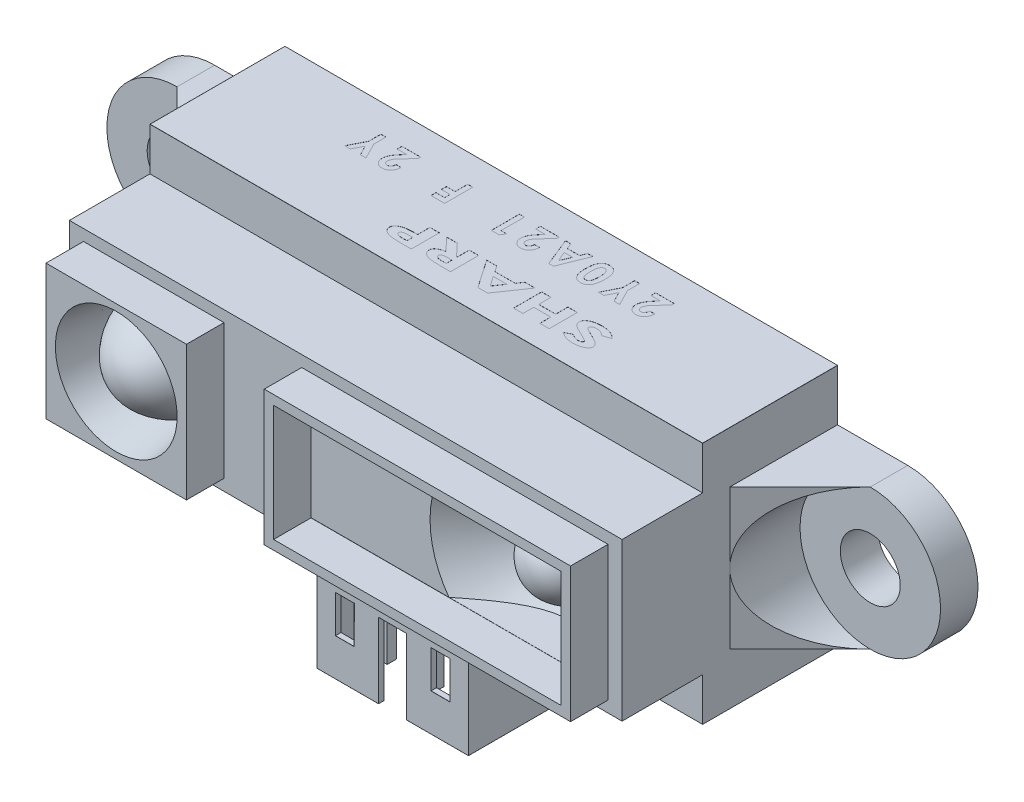
from build123d import *

# Parameters (mm, degrees)
SKETCH1_R           = 1.6
BOSS_EXTRUDE1_DEPTH = 13.5
CUT_EXTRUDE1_START  = -2
SKETCH3_R           = 3.75
CUT_EXTRUDE1_DEPTH  = 12.5
CUT_EXTRUDE2_DEPTH  = 11.25
CUT_EXTRUDE3_START  = -6.3
SKETCH5_W           = 29.5
SKETCH5_H           = 2.3
CUT_EXTRUDE3_DEPTH  = 7.3
CUT_EXTRUDE4_START  = -2
SKETCH6_W           = 29.5
SKETCH6_H           = 8.4
SKETCH6_W_2         = 7.5
SKETCH6_H_2         = 7.2
SKETCH6_W_3         = 16.35
CUT_EXTRUDE4_DEPTH  = 3
SKETCH7_R           = 3.25
CUT_EXTRUDE5_DEPTH  = 3
CUT_EXTRUDE5_TAPER  = 10
SKETCH9_W           = 15.35
SKETCH9_H           = 6.2
CUT_EXTRUDE6_DEPTH  = 2
BOSS_EXTRUDE2_START = -3.3
SKETCH12_W          = 10.1
SKETCH12_H          = 5.9
BOSS_EXTRUDE2_DEPTH = 1.2
SKETCH13_W          = 10.1
SKETCH13_H          = 2.7
CUT_EXTRUDE8_DEPTH  = 2.3
SKETCH14_W          = 8.1
SKETCH14_H          = 4.5
SKETCH14_W_2        = 7.5
SKETCH14_H_2        = 3.9
SKETCH14_W_3        = 0.5
SKETCH14_H_3        = 0.5
BOSS_EXTRUDE3_DEPTH = 8.2
BOSS_EXTRUDE4_START = 1.5
SKETCH15_W          = 7.5
SKETCH15_H          = 3.9
BOSS_EXTRUDE4_DEPTH = 1
CUT_EXTRUDE9_DEPTH  = 4.5
SKETCH17_W          = 8.1
SKETCH17_H          = 0.1
CUT_EXTRUDE10_DEPTH = 0.1
CHAMFER3_SIZE       = 0.05
SKETCH18_W          = 1.5
SKETCH18_H          = 4
SKETCH18_W_2        = 1
SKETCH18_H_2        = 2
CUT_EXTRUDE11_DEPTH = 0.3
FILLET1_R           = 0.005
CUT_EXTRUDE12_DEPTH = 0.005
SKETCH10_R          = 2.25
CUT_EXTRUDE13_DEPTH = 3
BOSS_EXTRUDE5_DEPTH = 4.3


with BuildPart() as part:
    # Sketch1 → Boss-Extrude1 (new body)
    with BuildSketch(Plane.XY):
        with BuildLine():
            Line((-18.5, 3.75), (-14.75, 3.75))
            Line((-14.75, 3.75), (-14.75, 6.5))
            Line((-14.75, 6.5), (14.75, 6.5))
            Line((14.75, 6.5), (14.75, 3.75))
            Line((14.75, 3.75), (18.5, 3.75))
            ThreePointArc((18.5, 3.75), (22.25, 0), (18.5, -3.75))
            Line((18.5, -3.75), (14.75, -3.75))
            Line((14.75, -3.75), (14.75, -6.5))
            Line((14.75, -6.5), (-14.75, -6.5))
            Line((-14.75, -6.5), (-14.75, -3.75))
            Line((-14.75, -3.75), (-18.5, -3.75))
            ThreePointArc((-18.5, -3.75), (-22.25, 0), (-18.5, 3.75))
        make_face()
        with Locations((-18.5, 0)):
            Circle(SKETCH1_R, mode=Mode.SUBTRACT)
        with Locations((18.5, 0)):
            Circle(SKETCH1_R, mode=Mode.SUBTRACT)
    extrude(amount=BOSS_EXTRUDE1_DEPTH)

    # Sketch3 → Cut-Extrude1 (cut, through all)
    with BuildSketch(Plane(origin=(0, 0, 0), x_dir=(-1, 0, 0), z_dir=(0, 0, -1)).offset(CUT_EXTRUDE1_START)):
        with Locations((-18.5, 0)):
            Circle(SKETCH3_R)
        with Locations((18.5, 0)):
            Circle(SKETCH3_R)
    extrude(amount=-CUT_EXTRUDE1_DEPTH, mode=Mode.SUBTRACT)

    # Sketch4 → Cut-Extrude2 (cut, through all)
    with BuildSketch(Plane.XZ.offset(3.75)):
        Polygon((22.25, 2), (18.5, 2), (14.75, 5.75), (14.75, 13.5), (22.25, 13.5), align=None)
        Polygon((-22.25, 2), (-18.5, 2), (-14.75, 5.75), (-14.75, 13.5), (-22.25, 13.5), align=None)
    extrude(amount=-CUT_EXTRUDE2_DEPTH, mode=Mode.SUBTRACT)

    # Sketch5 → Cut-Extrude3 (cut, through all)
    with BuildSketch(Plane.XY.offset(13.5).offset(CUT_EXTRUDE3_START)):
        with Locations((0, 5.35)):
            Rectangle(SKETCH5_W, SKETCH5_H)
        with Locations((0, -5.35)):
            Rectangle(SKETCH5_W, SKETCH5_H)
    extrude(amount=CUT_EXTRUDE3_DEPTH, mode=Mode.SUBTRACT)

    # Sketch6 → Cut-Extrude4 (cut, through all)
    with BuildSketch(Plane.XY.offset(13.5).offset(CUT_EXTRUDE4_START)):
        Rectangle(SKETCH6_W, SKETCH6_H)
        with Locations((-10.25, 0)):
            Rectangle(SKETCH6_W_2, SKETCH6_H_2, mode=Mode.SUBTRACT)
        with Locations((5.825, 0)):
            Rectangle(SKETCH6_W_3, SKETCH6_H_2, mode=Mode.SUBTRACT)
    extrude(amount=CUT_EXTRUDE4_DEPTH, mode=Mode.SUBTRACT)

    # Sketch7 → Cut-Extrude5 (cut)
    with BuildSketch(Plane.XY.offset(13.5)):
        with Locations((-10.25, 0)):
            Circle(SKETCH7_R)
    extrude(amount=-CUT_EXTRUDE5_DEPTH, taper=CUT_EXTRUDE5_TAPER, mode=Mode.SUBTRACT)

    # Sketch8 → Revolve1 (revolve)
    with BuildSketch(Plane(origin=(0, 0, 0), x_dir=(1, 0, 0), z_dir=(0, 1, 0))):
        with BuildLine():
            Line((-10.25, -10.5), (-7.528980942, -10.5))
            add(Edge.make_bspline(
                [(-7.528980942, -10.5), (-7.528980942, -11.5), (-8.583333333, -13.5), (-10.25, -13.5)],
                knots=[0, 0, 0, 0, 1, 1, 1, 1], degree=3))
            Line((-10.25, -13.5), (-10.25, -10.5))
        make_face()
    revolve(axis=Axis((-10.25, 0, 10.5), (0, 0, 1)))

    # Sketch9 → Cut-Extrude6 (cut)
    with BuildSketch(Plane.XY.offset(13.5)):
        with Locations((5.825, 0)):
            Rectangle(SKETCH9_W, SKETCH9_H)
    extrude(amount=-CUT_EXTRUDE6_DEPTH, mode=Mode.SUBTRACT)

    # Sketch12 → Boss-Extrude2 (add)
    with BuildSketch(Plane(origin=(0, 0, 0), x_dir=(-1, 0, 0), z_dir=(0, 0, -1)).offset(BOSS_EXTRUDE2_START)):
        with Locations((0, -9.45)):
            Rectangle(SKETCH12_W, SKETCH12_H)
    extrude(amount=-BOSS_EXTRUDE2_DEPTH)

    # Sketch13 → Cut-Extrude8 (cut)
    with BuildSketch(Plane.XZ.offset(6.5)):
        with Locations((0, 5.85)):
            Rectangle(SKETCH13_W, SKETCH13_H)
    extrude(amount=-CUT_EXTRUDE8_DEPTH, mode=Mode.SUBTRACT)

    # Sketch14 → Boss-Extrude3 (add, through all)
    with BuildSketch(Plane.XZ.offset(4.2)):
        with Locations((0, 6.75)):
            Rectangle(SKETCH14_W, SKETCH14_H)
        with Locations((0, 6.75)):
            Rectangle(SKETCH14_W_2, SKETCH14_H_2, mode=Mode.SUBTRACT)
        with Locations((0, 6.75)):
            Rectangle(SKETCH14_W_3, SKETCH14_H_3)
        with Locations((2.54, 6.75)):
            Rectangle(SKETCH14_W_3, SKETCH14_H_3)
        with Locations((-2.54, 6.75)):
            Rectangle(SKETCH14_W_3, SKETCH14_H_3)
    extrude(amount=BOSS_EXTRUDE3_DEPTH)

    # Sketch15 → Boss-Extrude4 (add)
    with BuildSketch(Plane.XZ.offset(4.2).offset(BOSS_EXTRUDE4_START)):
        with Locations((0, 6.75)):
            Rectangle(SKETCH15_W, SKETCH15_H)
    extrude(amount=BOSS_EXTRUDE4_DEPTH)

    # Sketch16 → Cut-Extrude9 (cut)
    with BuildSketch(Plane.XY.offset(9)):
        Polygon((-4.05, -4.2), (-4.05, -4.860219994), (-3.55, -4.860219994), (-3.55, -5.760219994), (3.55, -5.760219994), (3.55, -4.8), (4.05, -4.8), (4.05, -4.2), align=None)
    extrude(amount=-CUT_EXTRUDE9_DEPTH, mode=Mode.SUBTRACT)

    # Sketch17 → Cut-Extrude10 (cut)
    with BuildSketch(Plane(origin=(0, -12.4, 0), x_dir=(-1, 0, 0), z_dir=(0, -1, 0))):
        with Locations((0, -4.55)):
            Rectangle(SKETCH17_W, SKETCH17_H)
    extrude(amount=-CUT_EXTRUDE10_DEPTH, mode=Mode.SUBTRACT)

    # Chamfer3
    chamfer3_edges = [part.edges().sort_by_distance(p)[0] for p in [
        (0.25, -12.4, 6.75),
        (0, -12.4, 7),
        (-0.25, -12.4, 6.75),
        (0, -12.4, 6.5),
        (2.54, -12.4, 7),
        (2.79, -12.4, 6.75),
        (2.29, -12.4, 6.75),
        (2.54, -12.4, 6.5),
        (-2.29, -12.4, 6.75),
        (-2.54, -12.4, 7),
        (-2.79, -12.4, 6.75),
        (-2.54, -12.4, 6.5),
    ]]
    chamfer(chamfer3_edges, length=CHAMFER3_SIZE)

    # Sketch18 → Cut-Extrude11 (cut)
    with BuildSketch(Plane.XY.offset(9)):
        with Locations((0, -10.4)):
            Rectangle(SKETCH18_W, SKETCH18_H)
        with Locations((-2.55, -9.4)):
            Rectangle(SKETCH18_W_2, SKETCH18_H_2)
        with Locations((2.55, -9.4)):
            Rectangle(SKETCH18_W_2, SKETCH18_H_2)
    extrude(amount=-CUT_EXTRUDE11_DEPTH, mode=Mode.SUBTRACT)

    # Fillet1
    fillet1_edges = [part.edges().sort_by_distance(p)[0] for p in [
        (14.75, 6.5, 3.6),
        (-14.75, 6.5, 3.6),
        (0, 6.5, 7.2),
        (13.5, 0, 11.5),
        (5.825, -3.1, 11.5),
        (-2.4, -12.4, 9),
        (4.05, -8.6, 9),
        (3.75, -12.4, 6.75),
        (3.75, -9.55, 8.7),
        (0, -12.4, 4.8),
        (-3.75, -9.55, 8.7),
        (-4.05, -8.630109997, 9),
        (-3.75, -12.4, 6.75),
        (-2.25, -12.4, 8.7),
        (0, -6.7, 8.7),
        (-4.05, -4.860219994, 6.75),
        (-3.8, -4.860219994, 9),
        (-3.55, -5.310219994, 9),
        (0, -5.760219994, 9),
        (3.55, -5.280109997, 9),
        (3.8, -4.8, 9),
        (-3.8, -4.860219994, 4.5),
        (-4.05, -8.580109997, 4.5),
        (-4.05, -12.4, 6.8),
        (4.05, -12.4, 6.8),
        (0, -12.3, 4.5),
        (-4.05, -12.3, 4.55),
        (-4.05, -12.35, 4.6),
        (0, -12.4, 4.6),
        (2.4, -12.4, 9),
        (2.25, -12.4, 8.7),
        (2.05, -9.4, 9),
        (2.55, -10.4, 9),
        (3.05, -9.4, 9),
        (2.55, -8.4, 9),
        (2.05, -9.4, 8.7),
        (2.55, -8.4, 8.7),
        (3.05, -9.4, 8.7),
        (2.55, -10.4, 8.7),
        (-3.05, -9.4, 9),
        (-2.55, -10.4, 9),
        (-2.05, -9.4, 9),
        (-2.55, -8.4, 9),
        (-3.05, -9.4, 8.7),
        (-2.55, -8.4, 8.7),
        (-2.05, -9.4, 8.7),
        (-2.55, -10.4, 8.7),
        (-0.75, -12.4, 8.85),
        (0.75, -12.4, 8.85),
        (-0.75, -10.4, 9),
        (0.75, -10.4, 9),
        (0, -8.4, 9),
        (-0.75, -10.4, 8.7),
        (0, -8.4, 8.7),
        (0.75, -10.4, 8.7),
    ]]
    fillet(fillet1_edges, radius=FILLET1_R)

    # Sketch19 → Cut-Extrude12 (cut)
    with BuildSketch(Plane(origin=(0, 6.5, 0), x_dir=(1, 0, 0), z_dir=(0, 1, 0))):
        with BuildLine():
            Line((-2.003855433, -6), (-2.546223222, -6))
            add(Edge.make_bspline(
                [(-2.546223222, -6), (-2.581580758, -5.999913513), (-2.649798708, -5.999746648), (-2.748373771, -5.997668262), (-2.839227685, -5.994046889), (-2.922497136, -5.989412392), (-2.99793639, -5.983118091), (-3.065810461, -5.975780196), (-3.125983937, -5.966907417), (-3.1793444, -5.956377265), (-3.22747068, -5.943944163), (-3.272442089, -5.930660255), (-3.314685073, -5.914940864), (-3.354446077, -5.897876093), (-3.391624287, -5.879198773), (-3.426247625, -5.858844358), (-3.458236639, -5.836471428), (-3.487671043, -5.812575415), (-3.514019403, -5.78715296), (-3.537223483, -5.760593813), (-3.556520535, -5.732534132), (-3.572252501, -5.703168237), (-3.58461326, -5.672642205), (-3.593861938, -5.640883349), (-3.598879578, -5.607732702), (-3.599630645, -5.585251619), (-3.60000928, -5.573918269)],
                knots=[0, 0, 0, 0, 0.000106071, 0.000204652, 0.000295769, 0.000378841, 0.000454824, 0.000522848, 0.000583617, 0.000637242, 0.000685925, 0.000732694, 0.000777851, 0.000821054, 0.000862443, 0.000902588, 0.000941432, 0.000979445, 0.001016208, 0.001051147, 0.001085069, 0.00111814, 0.001150894, 0.001183707, 0.001217152, 0.001251154, 0.001251154, 0.001251154, 0.001251154], degree=3))
            add(Edge.make_bspline(
                [(-3.60000928, -5.573918269), (-3.599541213, -5.561364202), (-3.598616557, -5.536563911), (-3.591447175, -5.500311612), (-3.580118651, -5.465482861), (-3.563151829, -5.432737203), (-3.542450632, -5.401095142), (-3.516451786, -5.3716555), (-3.486308918, -5.343469381), (-3.451192625, -5.317658038), (-3.41254664, -5.292965856), (-3.370142717, -5.270581921), (-3.324454668, -5.250247369), (-3.2758844, -5.231083213), (-3.223522746, -5.214848406), (-3.168154519, -5.199768485), (-3.109397216, -5.186779698), (-3.068994361, -5.180099763), (-3.048326587, -5.176682692)],
                knots=[0, 0, 0, 0, 3.7637e-05, 7.4351e-05, 0.000110459, 0.000147144, 0.000184647, 0.000223627, 0.000264661, 0.000308231, 0.000354161, 0.00040215, 0.000451911, 0.00050414, 0.000558687, 0.000616271, 0.000676272, 0.000739109, 0.000739109, 0.000739109, 0.000739109], degree=3))
            add(Edge.make_bspline(
                [(-3.048326587, -5.176682692), (-3.034617929, -5.174764841), (-3.004669622, -5.170575051), (-2.955715955, -5.166443334), (-2.899121518, -5.162525243), (-2.834910763, -5.159225428), (-2.762980257, -5.156965579), (-2.683449491, -5.155197826), (-2.596207293, -5.153914008), (-2.535506584, -5.153869409), (-2.503855433, -5.153846154)],
                knots=[0, 0, 0, 0, 4.152e-05, 9.0705e-05, 0.00014733, 0.000211718, 0.000283573, 0.000363221, 0.000450369, 0.000545321, 0.000545321, 0.000545321, 0.000545321], degree=3))
            Line((-2.503855433, -5.153846154), (-2.503855433, -4.5))
            Line((-2.503855433, -4.5), (-2.003855433, -4.5))
            Line((-2.003855433, -4.5), (-2.003855433, -6))
        make_face()
        with BuildLine():
            Line((-2.503855433, -5.423076923), (-2.668218414, -5.423076923))
            add(Edge.make_bspline(
                [(-2.668218414, -5.423076923), (-2.683743374, -5.423158943), (-2.713592464, -5.423316639), (-2.756466468, -5.423832122), (-2.795739089, -5.424988596), (-2.831290326, -5.426871964), (-2.863172026, -5.428777624), (-2.891302901, -5.431625648), (-2.915802646, -5.434386248), (-2.942985481, -5.439128581), (-2.972620877, -5.446527626), (-3.00453605, -5.458006032), (-3.03274044, -5.471599342), (-3.056606604, -5.488089677), (-3.07582799, -5.506663052), (-3.089951675, -5.527294434), (-3.098513669, -5.550142582), (-3.09950714, -5.566135363), (-3.10000928, -5.57421875)],
                knots=[0, 0, 0, 0, 4.6575e-05, 8.9548e-05, 0.000128629, 0.000164432, 0.000196352, 0.000224428, 0.00024925, 0.000270294, 0.00030717, 0.000340723, 0.000371899, 0.000400824, 0.000427383, 0.000451635, 0.000475304, 0.000499495, 0.000499495, 0.000499495, 0.000499495], degree=3))
            add(Edge.make_bspline(
                [(-3.10000928, -5.57421875), (-3.099702522, -5.581270971), (-3.099100084, -5.595120787), (-3.093118924, -5.615088061), (-3.083290219, -5.63338096), (-3.069669431, -5.650183869), (-3.052411291, -5.665642105), (-3.030933307, -5.678914172), (-3.006247574, -5.691524557), (-2.987928279, -5.697753023), (-2.978314568, -5.701021635)],
                knots=[0, 0, 0, 0, 2.1111e-05, 4.1459e-05, 6.1892e-05, 8.3056e-05, 0.000106039, 0.000131044, 0.000158591, 0.000189013, 0.000189013, 0.000189013, 0.000189013], degree=3))
            add(Edge.make_bspline(
                [(-2.978314568, -5.701021635), (-2.970132043, -5.703445815), (-2.952433817, -5.708689146), (-2.923060231, -5.714444989), (-2.889069516, -5.719501788), (-2.850268178, -5.723618824), (-2.806775834, -5.726826247), (-2.758588652, -5.729296801), (-2.705682134, -5.730281745), (-2.66881944, -5.730602104), (-2.649588607, -5.730769231)],
                knots=[0, 0, 0, 0, 2.559e-05, 5.535e-05, 8.9686e-05, 0.000128676, 0.000172371, 0.000220508, 0.000273406, 0.000331102, 0.000331102, 0.000331102, 0.000331102], degree=3))
            Line((-2.649588607, -5.730769231), (-2.503855433, -5.730769231))
            Line((-2.503855433, -5.730769231), (-2.503855433, -5.423076923))
        make_face(mode=Mode.SUBTRACT)
        with BuildLine():
            Line((0.092298413, -6), (-0.443458799, -6))
            add(Edge.make_bspline(
                [(-0.443458799, -6), (-0.47881685, -5.999926021), (-0.546935654, -5.999783497), (-0.645099744, -5.997550308), (-0.735372204, -5.994473365), (-0.817711835, -5.989588475), (-0.89218974, -5.983851715), (-0.958714867, -5.976290334), (-1.017420532, -5.967869191), (-1.069060773, -5.957546333), (-1.11555333, -5.945523387), (-1.158862835, -5.931964949), (-1.200089034, -5.916958483), (-1.238561597, -5.899030986), (-1.275412562, -5.880896287), (-1.309452032, -5.859841867), (-1.341414669, -5.837319325), (-1.371048585, -5.813145387), (-1.397881313, -5.78756251), (-1.420703733, -5.760232259), (-1.44067635, -5.732234491), (-1.45640833, -5.702609966), (-1.469435292, -5.672175495), (-1.477876267, -5.64037163), (-1.483675442, -5.607583262), (-1.484304799, -5.585262555), (-1.484624664, -5.573918269)],
                knots=[0, 0, 0, 0, 0.000106071, 0.000204351, 0.000294556, 0.000377028, 0.000451789, 0.000518619, 0.000577857, 0.000629656, 0.000676517, 0.00072185, 0.000765776, 0.000808002, 0.000849123, 0.000888906, 0.000927924, 0.00096636, 0.001003548, 0.001038943, 0.001073037, 0.001106514, 0.001139382, 0.001172114, 0.001205014, 0.001239016, 0.001239016, 0.001239016, 0.001239016], degree=3))
            add(Edge.make_bspline(
                [(-1.484624664, -5.573918269), (-1.484214129, -5.5620723), (-1.483405046, -5.538726217), (-1.477176426, -5.504531248), (-1.467287243, -5.471665063), (-1.452994692, -5.440506138), (-1.435209361, -5.410484131), (-1.412522069, -5.38273902), (-1.386765533, -5.355656408), (-1.356218125, -5.330796298), (-1.322061936, -5.307011251), (-1.283547706, -5.285231483), (-1.241384508, -5.264399854), (-1.195033875, -5.245168201), (-1.144416064, -5.228009095), (-1.090026557, -5.211737733), (-1.031585238, -5.196959676), (-0.991072175, -5.188733146), (-0.970201587, -5.184495192)],
                knots=[0, 0, 0, 0, 3.5519e-05, 7.0001e-05, 0.000103934, 0.000138227, 0.000172599, 0.000208311, 0.000245499, 0.000284549, 0.000326225, 0.000370241, 0.00041714, 0.000467251, 0.000520655, 0.000577411, 0.000637535, 0.000701418, 0.000701418, 0.000701418, 0.000701418], degree=3))
            Line((-0.970201587, -5.184495192), (-1.609624664, -4.5))
            Line((-1.609624664, -4.5), (-1.044420337, -4.5))
            Line((-1.044420337, -4.5), (-0.433843414, -5.153846154))
            Line((-0.433843414, -5.153846154), (-0.407701587, -5.153846154))
            Line((-0.407701587, -5.153846154), (-0.407701587, -4.5))
            Line((-0.407701587, -4.5), (0.092298413, -4.5))
            Line((0.092298413, -4.5), (0.092298413, -6))
        make_face()
        with BuildLine():
            Line((-0.407701587, -5.423076923), (-0.56485303, -5.423076923))
            add(Edge.make_bspline(
                [(-0.56485303, -5.423076923), (-0.583983899, -5.423222702), (-0.620749359, -5.423502859), (-0.673666876, -5.424775991), (-0.721952419, -5.427877738), (-0.765537675, -5.431746727), (-0.804509217, -5.436264996), (-0.838672686, -5.442648017), (-0.868369779, -5.449648844), (-0.89364385, -5.458044117), (-0.915217351, -5.467801306), (-0.933721429, -5.478938995), (-0.949578623, -5.491514791), (-0.962381966, -5.505898992), (-0.972549638, -5.521645335), (-0.979369574, -5.539036921), (-0.983802598, -5.557772835), (-0.984344242, -5.570786528), (-0.984624664, -5.577524038)],
                knots=[0, 0, 0, 0, 5.7395e-05, 0.000110301, 0.000158772, 0.000202516, 0.000241575, 0.000276406, 0.000306724, 0.000333044, 0.000356172, 0.000377609, 0.000397694, 0.000416634, 0.00043514, 0.000453609, 0.000472415, 0.000492603, 0.000492603, 0.000492603, 0.000492603], degree=3))
            add(Edge.make_bspline(
                [(-0.984624664, -5.577524038), (-0.984159255, -5.585524164), (-0.983236194, -5.601391065), (-0.973976303, -5.624026924), (-0.959969223, -5.645153627), (-0.939983181, -5.663965775), (-0.915594807, -5.680522025), (-0.887398802, -5.695125434), (-0.855200729, -5.706585633), (-0.825542617, -5.714510223), (-0.798286965, -5.71905815), (-0.773648467, -5.722388748), (-0.745075575, -5.725015662), (-0.712602195, -5.726987952), (-0.676347352, -5.728858701), (-0.63617402, -5.730016843), (-0.592097989, -5.730529883), (-0.561347522, -5.730687229), (-0.54532178, -5.730769231)],
                knots=[0, 0, 0, 0, 2.3892e-05, 4.7385e-05, 7.2303e-05, 9.9503e-05, 0.000129092, 0.000160539, 0.000194478, 0.000231428, 0.000252473, 0.000277333, 0.000306006, 0.000338526, 0.000374929, 0.000414911, 0.000459086, 0.000507164, 0.000507164, 0.000507164, 0.000507164], degree=3))
            Line((-0.54532178, -5.730769231), (-0.407701587, -5.730769231))
            Line((-0.407701587, -5.730769231), (-0.407701587, -5.423076923))
        make_face(mode=Mode.SUBTRACT)
        Polygon((2.073067643, -6), (1.552935432, -6), (0.52499072, -4.5), (1.061348893, -4.5), (1.268981105, -4.807692308), (2.358524374, -4.807692308), (2.566156586, -4.5), (3.101913797, -4.5), align=None)
        Polygon((1.813452259, -5.59765625), (2.176433028, -5.076923077), (1.45077197, -5.076923077), align=None, mode=Mode.SUBTRACT)
        Polygon((5.361529182, -6), (4.861529182, -6), (4.861529182, -5.423076923), (3.957683028, -5.423076923), (3.957683028, -6), (3.457683028, -6), (3.457683028, -4.5), (3.957683028, -4.5), (3.957683028, -5.153846154), (4.861529182, -5.153846154), (4.861529182, -4.5), (5.361529182, -4.5), align=None)
        with BuildLine():
            Line((5.89999072, -5.799579327), (6.266577259, -5.615384615))
            add(Edge.make_bspline(
                [(6.266577259, -5.615384615), (6.282528593, -5.627647975), (6.313772624, -5.651668336), (6.362611113, -5.682820968), (6.411413867, -5.709546949), (6.460554008, -5.731294361), (6.510006159, -5.748273331), (6.559697604, -5.760267867), (6.609593131, -5.767845771), (6.642953272, -5.768769606), (6.659606105, -5.769230769)],
                knots=[0, 0, 0, 0, 6.0337e-05, 0.000118182, 0.000173578, 0.000227122, 0.000279195, 0.00033021, 0.000380311, 0.000430249, 0.000430249, 0.000430249, 0.000430249], degree=3))
            add(Edge.make_bspline(
                [(6.659606105, -5.769230769), (6.675152539, -5.768952342), (6.704859034, -5.768420318), (6.747133789, -5.76258908), (6.785090502, -5.753586071), (6.8178813, -5.74050972), (6.844759539, -5.725227591), (6.865157897, -5.709005451), (6.878087239, -5.690545019), (6.879904737, -5.677236032), (6.880759951, -5.670973558)],
                knots=[0, 0, 0, 0, 4.6609e-05, 8.9062e-05, 0.00012776, 0.000163359, 0.000194592, 0.000220177, 0.000241264, 0.000260005, 0.000260005, 0.000260005, 0.000260005], degree=3))
            add(Edge.make_bspline(
                [(6.880759951, -5.670973558), (6.880230063, -5.66467259), (6.879132485, -5.651621139), (6.869834585, -5.632835943), (6.855334387, -5.614896971), (6.842723174, -5.604637561), (6.835988317, -5.599158654)],
                knots=[0, 0, 0, 0, 1.8825e-05, 3.8993e-05, 6.1659e-05, 8.7636e-05, 8.7636e-05, 8.7636e-05, 8.7636e-05], degree=3))
            add(Edge.make_bspline(
                [(6.835988317, -5.599158654), (6.829721398, -5.594785833), (6.814901415, -5.584445005), (6.788015331, -5.568472271), (6.753408922, -5.549400949), (6.711324568, -5.526885065), (6.661653213, -5.501022195), (6.604373272, -5.471944576), (6.539319621, -5.439787441), (6.49335373, -5.417439968), (6.469101297, -5.405649038)],
                knots=[0, 0, 0, 0, 2.2919e-05, 5.42e-05, 9.3746e-05, 0.000141469, 0.000197379, 0.000261748, 0.000334179, 0.000415079, 0.000415079, 0.000415079, 0.000415079], degree=3))
            add(Edge.make_bspline(
                [(6.469101297, -5.405649038), (6.446360054, -5.394741593), (6.403261391, -5.374070061), (6.342142694, -5.344566503), (6.288066243, -5.318302716), (6.24131062, -5.29462369), (6.201225179, -5.27503256), (6.168410081, -5.258124992), (6.142620254, -5.244479346), (6.127940074, -5.23610557), (6.121745528, -5.232572115)],
                knots=[0, 0, 0, 0, 7.5665e-05, 0.000143399, 0.000203603, 0.000256011, 0.000300625, 0.000337447, 0.000366753, 0.000388146, 0.000388146, 0.000388146, 0.000388146], degree=3))
            add(Edge.make_bspline(
                [(6.121745528, -5.232572115), (6.109479365, -5.225336163), (6.085653095, -5.21128077), (6.051730658, -5.189568021), (6.020314073, -5.16845967), (5.992199808, -5.146841727), (5.966132681, -5.126389702), (5.943298975, -5.10564792), (5.923388743, -5.085033852), (5.900323388, -5.058815749), (5.877329028, -5.024389108), (5.857101939, -4.980865912), (5.844463742, -4.935299883), (5.843020657, -4.904124498), (5.842298413, -4.888521635)],
                knots=[0, 0, 0, 0, 4.272e-05, 8.2981e-05, 0.000120819, 0.000156216, 0.000189347, 0.000220191, 0.000248665, 0.000275293, 0.00032488, 0.000372204, 0.000418851, 0.000465589, 0.000465589, 0.000465589, 0.000465589], degree=3))
            add(Edge.make_bspline(
                [(5.842298413, -4.888521635), (5.842987999, -4.87333268), (5.844352223, -4.843284029), (5.855418316, -4.799365337), (5.872886933, -4.757531458), (5.897806228, -4.717891354), (5.929833061, -4.680562623), (5.968493312, -4.644965965), (6.014464422, -4.612023686), (6.066472414, -4.580951875), (6.124336137, -4.552967934), (6.186818049, -4.52837447), (6.253648446, -4.507711375), (6.324554885, -4.490467036), (6.399930017, -4.477940366), (6.479308525, -4.468202227), (6.562966545, -4.46246126), (6.62013416, -4.461850843), (6.649389759, -4.461538462)],
                knots=[0, 0, 0, 0, 4.5516e-05, 9.0045e-05, 0.000135024, 0.000181049, 0.000229872, 0.000282184, 0.000338319, 0.00039923, 0.000463735, 0.000530917, 0.000600484, 0.000673437, 0.00074966, 0.000829568, 0.000913296, 0.001001055, 0.001001055, 0.001001055, 0.001001055], degree=3))
            add(Edge.make_bspline(
                [(6.649389759, -4.461538462), (6.672431386, -4.461763099), (6.717842312, -4.46220582), (6.784799851, -4.465887065), (6.849557337, -4.471849574), (6.911922774, -4.4802028), (6.972119264, -4.490973412), (7.029916554, -4.504573655), (7.085626289, -4.5200975), (7.139066765, -4.538076986), (7.190268488, -4.559105833), (7.239944575, -4.581845186), (7.287241189, -4.608439481), (7.333081589, -4.637006741), (7.376534514, -4.66926054), (7.418844158, -4.703202198), (7.458583149, -4.740796807), (7.483560476, -4.767497276), (7.496144567, -4.780949519)],
                knots=[0, 0, 0, 0, 6.9121e-05, 0.000136225, 0.000201107, 0.000264171, 0.000324937, 0.000384486, 0.000442229, 0.000498387, 0.000553516, 0.000608228, 0.000662162, 0.000716182, 0.000770152, 0.000824402, 0.000878822, 0.000934079, 0.000934079, 0.000934079, 0.000934079], degree=3))
            Line((7.496144567, -4.780949519), (7.078476297, -4.923076923))
            add(Edge.make_bspline(
                [(7.078476297, -4.923076923), (7.0627281, -4.907741051), (7.031839986, -4.877661661), (6.981636561, -4.8386646), (6.93002863, -4.805124426), (6.876372465, -4.778094405), (6.820951416, -4.756732749), (6.763695935, -4.74184063), (6.704688219, -4.732440837), (6.664749543, -4.731330106), (6.644582067, -4.730769231)],
                knots=[0, 0, 0, 0, 6.5901e-05, 0.000129256, 0.000190351, 0.000250285, 0.000309158, 0.000368193, 0.000427476, 0.000487948, 0.000487948, 0.000487948, 0.000487948], degree=3))
            add(Edge.make_bspline(
                [(6.644582067, -4.730769231), (6.624117814, -4.731239715), (6.584619361, -4.732147807), (6.528032414, -4.740422849), (6.476193696, -4.753299352), (6.437299622, -4.769412451), (6.409412585, -4.78390988), (6.391701312, -4.795385869), (6.376393511, -4.806923026), (6.364306959, -4.819485894), (6.354512122, -4.832063833), (6.347279873, -4.845159872), (6.343337549, -4.858952626), (6.342643377, -4.868267613), (6.342298413, -4.872896635)],
                knots=[0, 0, 0, 0, 6.1358e-05, 0.000118428, 0.000171193, 0.000221189, 0.000244309, 0.000265396, 0.00028445, 0.000301661, 0.000317527, 0.00033218, 0.000346254, 0.000360158, 0.000360158, 0.000360158, 0.000360158], degree=3))
            add(Edge.make_bspline(
                [(6.342298413, -4.872896635), (6.343195503, -4.881543751), (6.345075351, -4.899663733), (6.35878569, -4.925948103), (6.3802125, -4.951483267), (6.40407459, -4.972501657), (6.428930972, -4.989646209), (6.453034651, -5.004898053), (6.481952112, -5.022189208), (6.516194261, -5.040422046), (6.555115926, -5.061128276), (6.599142268, -5.083173944), (6.648189557, -5.106876101), (6.682530481, -5.123122722), (6.70047149, -5.131610577)],
                knots=[0, 0, 0, 0, 2.5885e-05, 5.4242e-05, 8.7139e-05, 0.000125667, 0.000149176, 0.000177683, 0.000211231, 0.000250224, 0.000294042, 0.000343494, 0.000397921, 0.000457463, 0.000457463, 0.000457463, 0.000457463], degree=3))
            add(Edge.make_bspline(
                [(6.70047149, -5.131610577), (6.718017512, -5.139785747), (6.752375426, -5.155794035), (6.802469329, -5.179916179), (6.850330464, -5.202980751), (6.895714819, -5.22550153), (6.938604436, -5.247494679), (6.9792676, -5.26844441), (7.01748416, -5.288968181), (7.053369494, -5.308654948), (7.086917136, -5.327703163), (7.118003047, -5.345880335), (7.146732482, -5.363444493), (7.173166668, -5.380143625), (7.197126544, -5.39640259), (7.218878207, -5.411677684), (7.238176947, -5.426354445), (7.260086298, -5.444931521), (7.284702641, -5.467043224), (7.309852693, -5.49461673), (7.331737628, -5.521601839), (7.34982769, -5.548697125), (7.363213535, -5.576226452), (7.373528564, -5.603374593), (7.37935345, -5.630764618), (7.380294062, -5.649013933), (7.380759951, -5.658052885)],
                knots=[0, 0, 0, 0, 5.8071e-05, 0.000113711, 0.000166795, 0.000217457, 0.0002657, 0.000311394, 0.000354681, 0.000395833, 0.000434184, 0.000470413, 0.000503858, 0.0005352, 0.000564202, 0.000590715, 0.000614935, 0.000636903, 0.000676883, 0.000714096, 0.000748728, 0.000781064, 0.000811569, 0.000840373, 0.000868012, 0.000895137, 0.000895137, 0.000895137, 0.000895137], degree=3))
            add(Edge.make_bspline(
                [(7.380759951, -5.658052885), (7.380113626, -5.670934294), (7.378827905, -5.696559012), (7.368713265, -5.73419384), (7.352277457, -5.770323297), (7.329005831, -5.804904148), (7.299038803, -5.837681516), (7.263038291, -5.869412409), (7.220254798, -5.899229918), (7.172054436, -5.927878422), (7.118876933, -5.953609972), (7.062233544, -5.97662074), (7.002423715, -5.995707408), (6.93956911, -6.01132063), (6.873760946, -6.023643115), (6.804826825, -6.032258548), (6.732901959, -6.037395134), (6.683953552, -6.038101508), (6.659005143, -6.038461538)],
                knots=[0, 0, 0, 0, 3.8603e-05, 7.6793e-05, 0.000116059, 0.000157228, 0.000201272, 0.000248959, 0.0003009, 0.000357483, 0.000417016, 0.000477947, 0.000540759, 0.000605183, 0.000672131, 0.000741491, 0.000813487, 0.000888329, 0.000888329, 0.000888329, 0.000888329], degree=3))
            add(Edge.make_bspline(
                [(6.659005143, -6.038461538), (6.626629125, -6.037819411), (6.562534854, -6.036548201), (6.467655275, -6.02662244), (6.375047053, -6.010800689), (6.299435754, -5.991989001), (6.239384146, -5.973087634), (6.193532464, -5.956316263), (6.146790142, -5.936589191), (6.099192579, -5.914418182), (6.050605969, -5.889624486), (6.001087225, -5.862293236), (5.950553494, -5.832267011), (5.917048997, -5.810607115), (5.89999072, -5.799579327)],
                knots=[0, 0, 0, 0, 9.7112e-05, 0.00019225, 0.000285862, 0.000378781, 0.000425727, 0.000474683, 0.000525187, 0.000577885, 0.000632175, 0.000688795, 0.000747542, 0.000808475, 0.000808475, 0.000808475, 0.000808475], degree=3))
        make_face()
        Polygon((-7.419640926, -3), (-7.719220253, -3), (-7.986948618, -2.473858173), (-8.254676983, -3), (-8.55425631, -3), (-8.121564003, -2.149639423), (-8.121564003, -1.5), (-7.852333233, -1.5), (-7.852333233, -2.149639423), align=None)
        with BuildLine():
            Line((-6.310025541, -2.5), (-6.040794772, -2.5))
            add(Edge.make_bspline(
                [(-6.040794772, -2.5), (-6.041957082, -2.520366096), (-6.044228165, -2.560160226), (-6.053271871, -2.6179589), (-6.065358988, -2.672585653), (-6.081628547, -2.723876258), (-6.101668158, -2.771852262), (-6.125976584, -2.816354748), (-6.153828063, -2.857702596), (-6.185783993, -2.895170649), (-6.220547437, -2.928855567), (-6.258029275, -2.958303807), (-6.298123034, -2.982955836), (-6.340560616, -3.003178007), (-6.385175331, -3.019358348), (-6.432417948, -3.030170521), (-6.481871613, -3.037494214), (-6.515726951, -3.038134963), (-6.532982272, -3.038461538)],
                knots=[0, 0, 0, 0, 6.1164e-05, 0.000119511, 0.000175275, 0.000228872, 0.000280717, 0.000331005, 0.00038076, 0.000430007, 0.000478458, 0.000525763, 0.000572713, 0.000619349, 0.000666586, 0.000714761, 0.000764522, 0.000816248, 0.000816248, 0.000816248, 0.000816248], degree=3))
            add(Edge.make_bspline(
                [(-6.532982272, -3.038461538), (-6.554171978, -3.03784399), (-6.595557426, -3.036637862), (-6.655501721, -3.02502507), (-6.711842113, -3.007136816), (-6.764021849, -2.981408401), (-6.811767445, -2.948816666), (-6.854511309, -2.909539434), (-6.892449614, -2.864058493), (-6.924331664, -2.812706264), (-6.950263323, -2.758139947), (-6.968986571, -2.70204613), (-6.981147626, -2.645555819), (-6.982453652, -2.607531625), (-6.983102464, -2.588641827)],
                knots=[0, 0, 0, 0, 6.3504e-05, 0.000124029, 0.000182468, 0.000240387, 0.000297895, 0.000355319, 0.000413989, 0.000475016, 0.000536173, 0.000594801, 0.000652139, 0.000708744, 0.000708744, 0.000708744, 0.000708744], degree=3))
            add(Edge.make_bspline(
                [(-6.983102464, -2.588641827), (-6.982850808, -2.57721528), (-6.982344286, -2.554216465), (-6.978822371, -2.519413612), (-6.973538804, -2.483962837), (-6.965572469, -2.447894538), (-6.955637807, -2.411198595), (-6.943585587, -2.373765223), (-6.929136429, -2.335806531), (-6.912530746, -2.29689579), (-6.892722517, -2.256904706), (-6.869648744, -2.21524191), (-6.84267275, -2.17179276), (-6.812057899, -2.126692529), (-6.77801985, -2.079591454), (-6.740040506, -2.031047374), (-6.698606292, -1.980512232), (-6.669189577, -1.946738895), (-6.654076022, -1.929387019)],
                knots=[0, 0, 0, 0, 3.4276e-05, 6.8989e-05, 0.000104856, 0.00014175, 0.000179726, 0.000218876, 0.000259672, 0.000301534, 0.000345746, 0.000393493, 0.000444359, 0.000499114, 0.000556994, 0.000618662, 0.00068399, 0.00075302, 0.00075302, 0.00075302, 0.00075302], degree=3))
            Line((-6.654076022, -1.929387019), (-6.497525541, -1.75))
            Line((-6.497525541, -1.75), (-7.002333233, -1.75))
            Line((-7.002333233, -1.75), (-7.002333233, -1.5))
            Line((-7.002333233, -1.5), (-6.002333233, -1.5))
            Line((-6.002333233, -1.5), (-6.002333233, -1.636418269))
            Line((-6.002333233, -1.636418269), (-6.44644381, -2.109074519))
            add(Edge.make_bspline(
                [(-6.44644381, -2.109074519), (-6.459302156, -2.122861912), (-6.48420496, -2.149564002), (-6.519635775, -2.188781103), (-6.551709333, -2.225989162), (-6.579708473, -2.261619671), (-6.605327223, -2.294466226), (-6.626759192, -2.325770552), (-6.645423811, -2.354651066), (-6.664920977, -2.389855262), (-6.68386299, -2.431525413), (-6.701232514, -2.479501465), (-6.711714307, -2.525387675), (-6.713172265, -2.555341647), (-6.713871695, -2.569711538)],
                knots=[0, 0, 0, 0, 5.6557e-05, 0.000109535, 0.000158553, 0.000203885, 0.000245473, 0.000283481, 0.000317658, 0.000348594, 0.000404125, 0.000454778, 0.000501515, 0.000544611, 0.000544611, 0.000544611, 0.000544611], degree=3))
            add(Edge.make_bspline(
                [(-6.713871695, -2.569711538), (-6.713358273, -2.583617932), (-6.712363435, -2.6105638), (-6.701158465, -2.648782639), (-6.684393062, -2.683648489), (-6.660052875, -2.713573113), (-6.630674892, -2.738377844), (-6.596532794, -2.756554451), (-6.558253456, -2.767237704), (-6.531447586, -2.768553751), (-6.517657753, -2.769230769)],
                knots=[0, 0, 0, 0, 4.1598e-05, 8.0603e-05, 0.000118498, 0.000156978, 0.000195374, 0.000233146, 0.000272151, 0.000313474, 0.000313474, 0.000313474, 0.000313474], degree=3))
            add(Edge.make_bspline(
                [(-6.517657753, -2.769230769), (-6.510535154, -2.768978846), (-6.496513174, -2.768482896), (-6.475901961, -2.765181488), (-6.45628891, -2.759363101), (-6.437455718, -2.751567282), (-6.419603378, -2.741233868), (-6.402776919, -2.728496288), (-6.386799053, -2.713678234), (-6.371743061, -2.69682604), (-6.358040142, -2.678018986), (-6.34586926, -2.657428837), (-6.335805966, -2.635068373), (-6.326945877, -2.611232787), (-6.320112552, -2.585666065), (-6.315137044, -2.55852122), (-6.311354498, -2.529842416), (-6.310476585, -2.510128434), (-6.310025541, -2.5)],
                knots=[0, 0, 0, 0, 2.1368e-05, 4.2066e-05, 6.2415e-05, 8.2616e-05, 0.000103078, 0.000124111, 0.0001458, 0.000168358, 0.000191798, 0.000215503, 0.000239974, 0.000265261, 0.00029172, 0.000319241, 0.000348014, 0.000378416, 0.000378416, 0.000378416, 0.000378416], degree=3))
        make_face()
        Polygon((-3.221564003, -3), (-3.952333233, -3), (-3.952333233, -2.730769231), (-3.490794772, -2.730769231), (-3.490794772, -2.442307692), (-3.952333233, -2.442307692), (-3.952333233, -2.173076923), (-3.490794772, -2.173076923), (-3.490794772, -1.5), (-3.221564003, -1.5), align=None)
        Polygon((-0.313090445, -3), (-0.72925631, -3), (-0.72925631, -1.5), (-0.460025541, -1.5), (-0.460025541, -2.75), (-0.152333233, -2.75), align=None)
        with BuildLine():
            Line((1.082282151, -2.5), (1.351512921, -2.5))
            add(Edge.make_bspline(
                [(1.351512921, -2.5), (1.350350611, -2.520366096), (1.348079527, -2.560160226), (1.339035821, -2.6179589), (1.326948704, -2.672585653), (1.310679146, -2.723876258), (1.290639535, -2.771852262), (1.266331109, -2.816354748), (1.23847963, -2.857702596), (1.2065237, -2.895170649), (1.171760255, -2.928855567), (1.134278417, -2.958303807), (1.094184658, -2.982955836), (1.051747076, -3.003178007), (1.007132361, -3.019358348), (0.959889744, -3.030170521), (0.91043608, -3.037494214), (0.876580741, -3.038134963), (0.859325421, -3.038461538)],
                knots=[0, 0, 0, 0, 6.1164e-05, 0.000119511, 0.000175275, 0.000228872, 0.000280717, 0.000331005, 0.00038076, 0.000430007, 0.000478458, 0.000525763, 0.000572713, 0.000619349, 0.000666586, 0.000714761, 0.000764522, 0.000816248, 0.000816248, 0.000816248, 0.000816248], degree=3))
            add(Edge.make_bspline(
                [(0.859325421, -3.038461538), (0.838135715, -3.03784399), (0.796750266, -3.036637862), (0.736805972, -3.02502507), (0.68046558, -3.007136816), (0.628285844, -2.981408401), (0.580540248, -2.948816666), (0.537796383, -2.909539434), (0.499858079, -2.864058493), (0.467976028, -2.812706264), (0.442044369, -2.758139947), (0.423321121, -2.70204613), (0.411160066, -2.645555819), (0.40985404, -2.607531625), (0.409205228, -2.588641827)],
                knots=[0, 0, 0, 0, 6.3504e-05, 0.000124029, 0.000182468, 0.000240387, 0.000297895, 0.000355319, 0.000413989, 0.000475016, 0.000536173, 0.000594801, 0.000652139, 0.000708744, 0.000708744, 0.000708744, 0.000708744], degree=3))
            add(Edge.make_bspline(
                [(0.409205228, -2.588641827), (0.409456884, -2.57721528), (0.409963406, -2.554216465), (0.413485321, -2.519413612), (0.418768889, -2.483962837), (0.426735223, -2.447894538), (0.436669886, -2.411198595), (0.448722106, -2.373765223), (0.463171264, -2.335806531), (0.479776947, -2.29689579), (0.499585175, -2.256904706), (0.522658948, -2.21524191), (0.549634942, -2.17179276), (0.580249793, -2.126692529), (0.614287843, -2.079591454), (0.652267186, -2.031047374), (0.6937014, -1.980512232), (0.723118116, -1.946738895), (0.738231671, -1.929387019)],
                knots=[0, 0, 0, 0, 3.4276e-05, 6.8989e-05, 0.000104856, 0.00014175, 0.000179726, 0.000218876, 0.000259672, 0.000301534, 0.000345746, 0.000393493, 0.000444359, 0.000499114, 0.000556994, 0.000618662, 0.00068399, 0.00075302, 0.00075302, 0.00075302, 0.00075302], degree=3))
            Line((0.738231671, -1.929387019), (0.894782151, -1.75))
            Line((0.894782151, -1.75), (0.389974459, -1.75))
            Line((0.389974459, -1.75), (0.389974459, -1.5))
            Line((0.389974459, -1.5), (1.389974459, -1.5))
            Line((1.389974459, -1.5), (1.389974459, -1.636418269))
            Line((1.389974459, -1.636418269), (0.945863882, -2.109074519))
            add(Edge.make_bspline(
                [(0.945863882, -2.109074519), (0.933005536, -2.122861912), (0.908102733, -2.149564002), (0.872671917, -2.188781103), (0.840598359, -2.225989162), (0.812599219, -2.261619671), (0.786980469, -2.294466226), (0.7655485, -2.325770552), (0.746883881, -2.354651066), (0.727386715, -2.389855262), (0.708444702, -2.431525413), (0.691075179, -2.479501465), (0.680593385, -2.525387675), (0.679135427, -2.555341647), (0.678435997, -2.569711538)],
                knots=[0, 0, 0, 0, 5.6557e-05, 0.000109535, 0.000158553, 0.000203885, 0.000245473, 0.000283481, 0.000317658, 0.000348594, 0.000404125, 0.000454778, 0.000501515, 0.000544611, 0.000544611, 0.000544611, 0.000544611], degree=3))
            add(Edge.make_bspline(
                [(0.678435997, -2.569711538), (0.67894942, -2.583617932), (0.679944258, -2.6105638), (0.691149227, -2.648782639), (0.707914631, -2.683648489), (0.732254817, -2.713573113), (0.7616328, -2.738377844), (0.795774899, -2.756554451), (0.834054236, -2.767237704), (0.860860106, -2.768553751), (0.87464994, -2.769230769)],
                knots=[0, 0, 0, 0, 4.1598e-05, 8.0603e-05, 0.000118498, 0.000156978, 0.000195374, 0.000233146, 0.000272151, 0.000313474, 0.000313474, 0.000313474, 0.000313474], degree=3))
            add(Edge.make_bspline(
                [(0.87464994, -2.769230769), (0.881772538, -2.768978846), (0.895794518, -2.768482896), (0.916405731, -2.765181488), (0.936018782, -2.759363101), (0.954851974, -2.751567282), (0.972704314, -2.741233868), (0.989530773, -2.728496288), (1.005508639, -2.713678234), (1.020564632, -2.69682604), (1.03426755, -2.678018986), (1.046438432, -2.657428837), (1.056501726, -2.635068373), (1.065361815, -2.611232787), (1.07219514, -2.585666065), (1.077170648, -2.55852122), (1.080953195, -2.529842416), (1.081831107, -2.510128434), (1.082282151, -2.5)],
                knots=[0, 0, 0, 0, 2.1368e-05, 4.2066e-05, 6.2415e-05, 8.2616e-05, 0.000103078, 0.000124111, 0.0001458, 0.000168358, 0.000191798, 0.000215503, 0.000239974, 0.000265261, 0.00029172, 0.000319241, 0.000348014, 0.000378416, 0.000378416, 0.000378416, 0.000378416], degree=3))
        make_face()
        Polygon((2.585827824, -3), (2.336128305, -3), (1.730359074, -1.5), (2.017919171, -1.5), (2.134505709, -1.807692308), (2.788051382, -1.807692308), (2.904637921, -1.5), (3.191897536, -1.5), align=None)
        Polygon((2.461128305, -2.59765625), (2.685887921, -2.076923077), (2.23636869, -2.076923077), align=None, mode=Mode.SUBTRACT)
        with BuildLine():
            add(Edge.make_bspline(
                [(4.065635517, -3.038461538), (4.052603596, -3.038268141), (4.02697936, -3.037887869), (3.989240257, -3.033766931), (3.952884859, -3.027546083), (3.91778123, -3.018853377), (3.884144659, -3.007409197), (3.85182938, -2.993479111), (3.82075638, -2.977321675), (3.791206704, -2.958287116), (3.76330036, -2.936629331), (3.736845042, -2.912413633), (3.712386859, -2.885246899), (3.689056774, -2.85579231), (3.667780253, -2.82340091), (3.64795055, -2.78860125), (3.629869194, -2.7510213), (3.613283972, -2.710635319), (3.598447644, -2.666827602), (3.585986096, -2.619091797), (3.575152452, -2.567461821), (3.566620635, -2.511668787), (3.55963755, -2.45184428), (3.555074879, -2.38787636), (3.55190077, -2.319944038), (3.551644553, -2.27334135), (3.551512921, -2.249399038)],
                knots=[0, 0, 0, 0, 3.9081e-05, 7.6844e-05, 0.000113745, 0.000149674, 0.000185212, 0.000220209, 0.000255154, 0.000290161, 0.000325501, 0.000361015, 0.0003976, 0.000435049, 0.000473635, 0.000513738, 0.00055513, 0.000598654, 0.000644644, 0.000693769, 0.000746572, 0.000802839, 0.000863033, 0.000927216, 0.000995191, 0.001067012, 0.001067012, 0.001067012, 0.001067012], degree=3))
            add(Edge.make_bspline(
                [(3.551512921, -2.249399038), (3.5516562, -2.225157337), (3.55193459, -2.178056146), (3.554933246, -2.109500354), (3.560098706, -2.045075379), (3.566751201, -1.984786191), (3.575880928, -1.928670375), (3.586496624, -1.87665796), (3.599295187, -1.828735658), (3.614539788, -1.784911233), (3.631109239, -1.744390487), (3.649080608, -1.706867006), (3.668442254, -1.672046513), (3.688984379, -1.63984749), (3.711384177, -1.610668948), (3.734715591, -1.584084922), (3.759644569, -1.560467486), (3.785768616, -1.539310339), (3.813730203, -1.520791756), (3.843404332, -1.504881527), (3.874991773, -1.49173328), (3.908032859, -1.480400285), (3.943115426, -1.472246748), (3.979697777, -1.465782511), (4.018188482, -1.462208819), (4.044394676, -1.461765581), (4.057823017, -1.461538462)],
                knots=[0, 0, 0, 0, 7.2722e-05, 0.000141297, 0.000205803, 0.000266594, 0.000323205, 0.000376302, 0.000425795, 0.000471882, 0.000515406, 0.000557069, 0.000596615, 0.000634872, 0.000671532, 0.000706866, 0.000740872, 0.000774425, 0.000807594, 0.000841336, 0.000875268, 0.000910141, 0.000945998, 0.000983195, 0.001021526, 0.001061809, 0.001061809, 0.001061809, 0.001061809], degree=3))
            add(Edge.make_bspline(
                [(4.057823017, -1.461538462), (4.071250706, -1.461770986), (4.097555352, -1.462226498), (4.136154191, -1.465744592), (4.173011789, -1.472330465), (4.20842526, -1.480342016), (4.242057779, -1.491817738), (4.274292345, -1.505085714), (4.304578012, -1.521514715), (4.333473708, -1.539872003), (4.360517081, -1.561032152), (4.386110615, -1.584657641), (4.410611878, -1.610418669), (4.4331481, -1.639210002), (4.454122268, -1.670505827), (4.473757194, -1.704301745), (4.491653205, -1.740708364), (4.508412183, -1.779715331), (4.523228562, -1.822260686), (4.536049008, -1.868735913), (4.546728345, -1.919540265), (4.55587107, -1.974448525), (4.562069964, -2.033777102), (4.567354195, -2.097176248), (4.570314542, -2.164835511), (4.570597834, -2.21133549), (4.57074369, -2.235276442)],
                knots=[0, 0, 0, 0, 4.0282e-05, 7.8913e-05, 0.00011611, 0.000152552, 0.000187709, 0.000222588, 0.000257002, 0.000290926, 0.000325186, 0.000359851, 0.000395349, 0.000431719, 0.000469388, 0.000508299, 0.000548882, 0.00059102, 0.000635589, 0.000683923, 0.00073555, 0.000791272, 0.000850834, 0.000914441, 0.000982116, 0.001053937, 0.001053937, 0.001053937, 0.001053937], degree=3))
            add(Edge.make_bspline(
                [(4.57074369, -2.235276442), (4.570482493, -2.26854039), (4.569978511, -2.332723604), (4.563755431, -2.425462768), (4.554341604, -2.511120532), (4.541454798, -2.589800394), (4.524097675, -2.661348354), (4.502796726, -2.725743859), (4.478355315, -2.783624343), (4.457561208, -2.817918644), (4.447546574, -2.834435096)],
                knots=[0, 0, 0, 0, 9.9776e-05, 0.000192519, 0.000278694, 0.000358226, 0.000431542, 0.000499291, 0.000561592, 0.000619473, 0.000619473, 0.000619473, 0.000619473], degree=3))
            add(Edge.make_bspline(
                [(4.447546574, -2.834435096), (4.435899708, -2.850660404), (4.413127789, -2.882384078), (4.373310452, -2.924031332), (4.330531907, -2.959650103), (4.283913508, -2.988434306), (4.234192544, -3.011133531), (4.180942136, -3.027165738), (4.124358927, -3.036506849), (4.085502294, -3.037800245), (4.065635517, -3.038461538)],
                knots=[0, 0, 0, 0, 5.9856e-05, 0.00011703, 0.000172316, 0.000226431, 0.000280892, 0.000335835, 0.000392792, 0.000452379, 0.000452379, 0.000452379, 0.000452379], degree=3))
        make_face()
        with BuildLine():
            add(Edge.make_bspline(
                [(4.05902494, -2.769230769), (4.070802494, -2.768666384), (4.093892751, -2.767559889), (4.127367551, -2.758377151), (4.158656496, -2.743777221), (4.182872867, -2.726999331), (4.200712862, -2.710283267), (4.213702924, -2.695635689), (4.225332113, -2.678491004), (4.236539711, -2.65959915), (4.246613402, -2.638384348), (4.256320825, -2.615415394), (4.264616037, -2.590115895), (4.272546294, -2.562702468), (4.279390345, -2.532496509), (4.285423236, -2.499215548), (4.290380603, -2.462712142), (4.294705623, -2.42294599), (4.297416045, -2.379925977), (4.300052255, -2.333662754), (4.301009892, -2.284057843), (4.301341689, -2.249899692), (4.301512921, -2.232271635)],
                knots=[0, 0, 0, 0, 3.5284e-05, 6.9176e-05, 0.000103321, 0.000138498, 0.000156994, 0.000176583, 0.000197089, 0.000219042, 0.000242426, 0.000267481, 0.000293802, 0.00032224, 0.000353073, 0.000386667, 0.00042368, 0.000463566, 0.00050664, 0.000552976, 0.00060257, 0.000655458, 0.000655458, 0.000655458, 0.000655458], degree=3))
            add(Edge.make_bspline(
                [(4.301512921, -2.232271635), (4.301237979, -2.209433153), (4.300710758, -2.165638671), (4.297957246, -2.102660976), (4.292404892, -2.045246401), (4.28557186, -1.993207935), (4.275999329, -1.946709117), (4.264278219, -1.905761663), (4.25121798, -1.869906077), (4.234850986, -1.839756929), (4.21731358, -1.81397348), (4.198595538, -1.791669446), (4.178369956, -1.773089929), (4.157241494, -1.757316286), (4.134426592, -1.745603434), (4.110393083, -1.737064388), (4.085087614, -1.731857929), (4.067762719, -1.731134228), (4.05902494, -1.730769231)],
                knots=[0, 0, 0, 0, 6.852e-05, 0.000131392, 0.000189039, 0.00024152, 0.000288782, 0.000331295, 0.000369242, 0.000402984, 0.000433905, 0.000462683, 0.000490113, 0.000516137, 0.000541538, 0.000566723, 0.000592475, 0.000618679, 0.000618679, 0.000618679, 0.000618679], degree=3))
            add(Edge.make_bspline(
                [(4.05902494, -1.730769231), (4.050586688, -1.731018693), (4.034065641, -1.731507108), (4.009974255, -1.736520629), (3.987191727, -1.744671526), (3.965786848, -1.756201541), (3.945683052, -1.770863719), (3.926978597, -1.788722492), (3.909814547, -1.809955871), (3.899814693, -1.825714178), (3.894661959, -1.833834135)],
                knots=[0, 0, 0, 0, 2.5285e-05, 4.9505e-05, 7.3457e-05, 9.7654e-05, 0.000122176, 0.000147893, 0.000175018, 0.000203854, 0.000203854, 0.000203854, 0.000203854], degree=3))
            add(Edge.make_bspline(
                [(3.894661959, -1.833834135), (3.888593609, -1.844929424), (3.87586877, -1.868195347), (3.861180908, -1.907463531), (3.848651036, -1.951695773), (3.83860675, -2.001249717), (3.830651002, -2.055926529), (3.82456883, -2.115766847), (3.821479491, -2.180856445), (3.82099532, -2.225958766), (3.82074369, -2.249399038)],
                knots=[0, 0, 0, 0, 3.7899e-05, 7.9471e-05, 0.000125409, 0.000175735, 0.000231021, 0.000291118, 0.000356106, 0.000426429, 0.000426429, 0.000426429, 0.000426429], degree=3))
            add(Edge.make_bspline(
                [(3.82074369, -2.249399038), (3.820842623, -2.273042056), (3.821033054, -2.31855083), (3.82452691, -2.383884025), (3.829392364, -2.443555065), (3.836509143, -2.497430689), (3.845666098, -2.545641811), (3.856952313, -2.588184874), (3.870257195, -2.625145), (3.886037487, -2.656481321), (3.903507933, -2.683122323), (3.922077137, -2.705946668), (3.941777209, -2.725596649), (3.962820409, -2.741523793), (3.985066305, -2.754218133), (4.008634923, -2.762869057), (4.033447859, -2.768190814), (4.050384171, -2.768879439), (4.05902494, -2.769230769)],
                knots=[0, 0, 0, 0, 7.0919e-05, 0.000136507, 0.000196221, 0.000250489, 0.00029946, 0.000343339, 0.000382412, 0.000417082, 0.000448335, 0.000477807, 0.000505216, 0.000531599, 0.000556757, 0.000581762, 0.000606631, 0.000632535, 0.000632535, 0.000632535, 0.000632535], degree=3))
        make_face(mode=Mode.SUBTRACT)
        Polygon((6.122666767, -3), (5.82308744, -3), (5.555359074, -2.473858173), (5.287630709, -3), (4.988051382, -3), (5.42074369, -2.149639423), (5.42074369, -1.5), (5.689974459, -1.5), (5.689974459, -2.149639423), align=None)
        with BuildLine():
            Line((7.232282151, -2.5), (7.501512921, -2.5))
            add(Edge.make_bspline(
                [(7.501512921, -2.5), (7.500350611, -2.520366096), (7.498079527, -2.560160226), (7.489035821, -2.6179589), (7.476948704, -2.672585653), (7.460679146, -2.723876258), (7.440639535, -2.771852262), (7.416331109, -2.816354748), (7.38847963, -2.857702596), (7.3565237, -2.895170649), (7.321760255, -2.928855567), (7.284278417, -2.958303807), (7.244184658, -2.982955836), (7.201747076, -3.003178007), (7.157132361, -3.019358348), (7.109889744, -3.030170521), (7.06043608, -3.037494214), (7.026580741, -3.038134963), (7.009325421, -3.038461538)],
                knots=[0, 0, 0, 0, 6.1164e-05, 0.000119511, 0.000175275, 0.000228872, 0.000280717, 0.000331005, 0.00038076, 0.000430007, 0.000478458, 0.000525763, 0.000572713, 0.000619349, 0.000666586, 0.000714761, 0.000764522, 0.000816248, 0.000816248, 0.000816248, 0.000816248], degree=3))
            add(Edge.make_bspline(
                [(7.009325421, -3.038461538), (6.988135715, -3.03784399), (6.946750266, -3.036637862), (6.886805972, -3.02502507), (6.83046558, -3.007136816), (6.778285844, -2.981408401), (6.730540248, -2.948816666), (6.687796383, -2.909539434), (6.649858079, -2.864058493), (6.617976028, -2.812706264), (6.592044369, -2.758139947), (6.573321121, -2.70204613), (6.561160066, -2.645555819), (6.55985404, -2.607531625), (6.559205228, -2.588641827)],
                knots=[0, 0, 0, 0, 6.3504e-05, 0.000124029, 0.000182468, 0.000240387, 0.000297895, 0.000355319, 0.000413989, 0.000475016, 0.000536173, 0.000594801, 0.000652139, 0.000708744, 0.000708744, 0.000708744, 0.000708744], degree=3))
            add(Edge.make_bspline(
                [(6.559205228, -2.588641827), (6.559456884, -2.57721528), (6.559963406, -2.554216465), (6.563485321, -2.519413612), (6.568768889, -2.483962837), (6.576735223, -2.447894538), (6.586669886, -2.411198595), (6.598722106, -2.373765223), (6.613171264, -2.335806531), (6.629776947, -2.29689579), (6.649585175, -2.256904706), (6.672658948, -2.21524191), (6.699634942, -2.17179276), (6.730249793, -2.126692529), (6.764287843, -2.079591454), (6.802267186, -2.031047374), (6.8437014, -1.980512232), (6.873118116, -1.946738895), (6.888231671, -1.929387019)],
                knots=[0, 0, 0, 0, 3.4276e-05, 6.8989e-05, 0.000104856, 0.00014175, 0.000179726, 0.000218876, 0.000259672, 0.000301534, 0.000345746, 0.000393493, 0.000444359, 0.000499114, 0.000556994, 0.000618662, 0.00068399, 0.00075302, 0.00075302, 0.00075302, 0.00075302], degree=3))
            Line((6.888231671, -1.929387019), (7.044782151, -1.75))
            Line((7.044782151, -1.75), (6.539974459, -1.75))
            Line((6.539974459, -1.75), (6.539974459, -1.5))
            Line((6.539974459, -1.5), (7.539974459, -1.5))
            Line((7.539974459, -1.5), (7.539974459, -1.636418269))
            Line((7.539974459, -1.636418269), (7.095863882, -2.109074519))
            add(Edge.make_bspline(
                [(7.095863882, -2.109074519), (7.083005536, -2.122861912), (7.058102733, -2.149564002), (7.022671917, -2.188781103), (6.990598359, -2.225989162), (6.962599219, -2.261619671), (6.936980469, -2.294466226), (6.9155485, -2.325770552), (6.896883881, -2.354651066), (6.877386715, -2.389855262), (6.858444702, -2.431525413), (6.841075179, -2.479501465), (6.830593385, -2.525387675), (6.829135427, -2.555341647), (6.828435997, -2.569711538)],
                knots=[0, 0, 0, 0, 5.6557e-05, 0.000109535, 0.000158553, 0.000203885, 0.000245473, 0.000283481, 0.000317658, 0.000348594, 0.000404125, 0.000454778, 0.000501515, 0.000544611, 0.000544611, 0.000544611, 0.000544611], degree=3))
            add(Edge.make_bspline(
                [(6.828435997, -2.569711538), (6.82894942, -2.583617932), (6.829944258, -2.6105638), (6.841149227, -2.648782639), (6.857914631, -2.683648489), (6.882254817, -2.713573113), (6.9116328, -2.738377844), (6.945774899, -2.756554451), (6.984054236, -2.767237704), (7.010860106, -2.768553751), (7.02464994, -2.769230769)],
                knots=[0, 0, 0, 0, 4.1598e-05, 8.0603e-05, 0.000118498, 0.000156978, 0.000195374, 0.000233146, 0.000272151, 0.000313474, 0.000313474, 0.000313474, 0.000313474], degree=3))
            add(Edge.make_bspline(
                [(7.02464994, -2.769230769), (7.031772538, -2.768978846), (7.045794518, -2.768482896), (7.066405731, -2.765181488), (7.086018782, -2.759363101), (7.104851974, -2.751567282), (7.122704314, -2.741233868), (7.139530773, -2.728496288), (7.155508639, -2.713678234), (7.170564632, -2.69682604), (7.18426755, -2.678018986), (7.196438432, -2.657428837), (7.206501726, -2.635068373), (7.215361815, -2.611232787), (7.22219514, -2.585666065), (7.227170648, -2.55852122), (7.230953195, -2.529842416), (7.231831107, -2.510128434), (7.232282151, -2.5)],
                knots=[0, 0, 0, 0, 2.1368e-05, 4.2066e-05, 6.2415e-05, 8.2616e-05, 0.000103078, 0.000124111, 0.0001458, 0.000168358, 0.000191798, 0.000215503, 0.000239974, 0.000265261, 0.00029172, 0.000319241, 0.000348014, 0.000378416, 0.000378416, 0.000378416, 0.000378416], degree=3))
        make_face()
    extrude(amount=-CUT_EXTRUDE12_DEPTH, mode=Mode.SUBTRACT)

    # Sketch10 → Cut-Extrude13 (cut)
    with BuildSketch(Plane.XY.offset(11.5)):
        with Locations((9.75, 0)):
            Circle(SKETCH10_R)
    extrude(amount=-CUT_EXTRUDE13_DEPTH, mode=Mode.SUBTRACT)

    # Cut-Sweep1: sweep along a path in Sketch22
    with BuildLine(Plane.XY.offset(8.5)) as cut_sweep1_path:
        CenterArc((9.75, 0), 2.25, 0, 360)
    # Sketch21 → Cut-Sweep1 (sweep, cut)
    with BuildSketch(Plane(origin=(0, 0, 0), x_dir=(1, 0, 0), z_dir=(0, 1, 0))):
        Polygon((4.5, -11.5), (9.75, -11.5), (9.75, -8.5), (7.5, -8.5), align=None)
    sweep(path=cut_sweep1_path.line, mode=Mode.SUBTRACT)

    # Sketch24 → Boss-Extrude5 (add)
    with BuildSketch(Plane.XY.offset(11.5)):
        Polygon((4.046146239, 3.1), (4.046146239, 4.2), (14.75, 4.2), (14.75, -4.2), (4.046146239, -4.2), (4.046146239, -3.095), (13.5, -3.095), (13.5, 3.1), align=None)
    extrude(amount=-BOSS_EXTRUDE5_DEPTH)

    # Sketch25 → Revolve4 (revolve)
    with BuildSketch(Plane(origin=(0, 0, 0), x_dir=(1, 0, 0), z_dir=(0, 1, 0))):
        with BuildLine():
            Line((9.75, -8.5), (12, -8.5))
            add(Edge.make_bspline(
                [(12, -8.5), (12, -9.5), (11.416666667, -11.5), (9.75, -11.5)],
                knots=[0, 0, 0, 0, 1, 1, 1, 1], degree=3))
            Line((9.75, -11.5), (9.75, -8.5))
        make_face()
    revolve(axis=Axis((9.75, 0, 8.5), (0, 0, 1)))


solid = part.part
